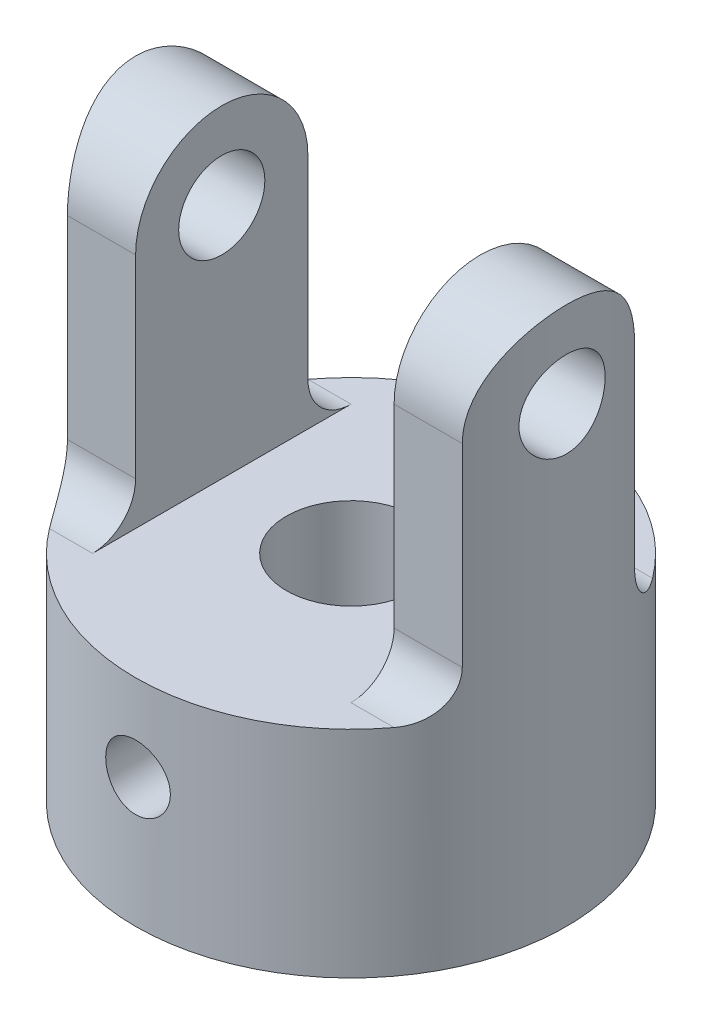
from build123d import *

# Parameters (mm, degrees)
SKETCH_1_W          = 20
SKETCH_1_H          = 20
EXTRUDE_1_DEPTH     = 10
SKETCH_2_R          = 2
EXTRUDE_2_DEPTH     = 10
SKETCH_2_2_R        = 2
CUT_EXTRUDE_1_DEPTH = 6
SKETCH_4_OUTSIDE_W  = 29.55
SKETCH_4_OUTSIDE_H  = 29.55
SKETCH_4_OUTSIDE_R  = 10
CUT_EXTRUDE_2_DEPTH = 29.722813233
SKETCH_5_R          = 3
CUT_EXTRUDE_3_DEPTH = 29.722813389
SKETCH_6_R          = 1.5
CUT_EXTRUDE_4_DEPTH = 29.722813389
FILLET_1_R          = 2


with BuildPart() as part:
    # 草圖1 → 填料-伸長1 (new body)
    with BuildSketch(Plane(origin=(0, 0, 0), x_dir=(1, 0, 0), z_dir=(0, 1, 0))):
        Rectangle(SKETCH_1_W, SKETCH_1_H)
    extrude(amount=EXTRUDE_1_DEPTH)

    # 草圖2 → 填料-伸長2 (add, symmetric)
    with BuildSketch(Plane(origin=(0, 0, 0), x_dir=(0, 0, -1), z_dir=(1, 0, 0))):
        with BuildLine():
            Line((4, 10), (4, 21))
            ThreePointArc((4, 21), (0, 25), (-4, 21))
            Line((-4, 21), (-4, 10))
            Line((-4, 10), (4, 10))
        make_face()
        with Locations((0, 21)):
            Circle(SKETCH_2_R, mode=Mode.SUBTRACT)
    extrude(amount=EXTRUDE_2_DEPTH, both=True)

    # 草圖2<2> → 除料-伸長1 (cut, symmetric)
    with BuildSketch(Plane(origin=(0, 0, 0), x_dir=(0, 0, -1), z_dir=(1, 0, 0))):
        with BuildLine():
            Line((4, 10), (4, 21))
            ThreePointArc((4, 21), (0, 25), (-4, 21))
            Line((-4, 21), (-4, 10))
            Line((-4, 10), (4, 10))
        make_face()
        with Locations((0, 21)):
            Circle(SKETCH_2_2_R, mode=Mode.SUBTRACT)
    extrude(amount=CUT_EXTRUDE_1_DEPTH, both=True, mode=Mode.SUBTRACT)

    # 草圖4 outside → 除料-伸長2 (cut, through all)
    with BuildSketch(Plane(origin=(0, 0, 0), x_dir=(1, 0, 0), z_dir=(0, 1, 0))):
        Rectangle(SKETCH_4_OUTSIDE_W, SKETCH_4_OUTSIDE_H)
        Circle(SKETCH_4_OUTSIDE_R, mode=Mode.SUBTRACT)
    extrude(amount=CUT_EXTRUDE_2_DEPTH, mode=Mode.SUBTRACT)

    # 草圖5 → 除料-伸長3 (cut, through all)
    with BuildSketch(Plane.XZ):
        Circle(SKETCH_5_R)
    extrude(amount=-CUT_EXTRUDE_3_DEPTH, mode=Mode.SUBTRACT)

    # 草圖6 → 除料-伸長4 (cut, through all)
    with BuildSketch(Plane.XY):
        with Locations((0, 6)):
            Circle(SKETCH_6_R)
    extrude(amount=CUT_EXTRUDE_4_DEPTH, mode=Mode.SUBTRACT)

    # 圓角1
    fillet_1_edges = [part.edges().sort_by_distance(p)[0] for p in [
        (-7.582575695, 10, -4),
        (7.582575695, 10, -4),
        (-7.582575695, 10, 4),
        (7.582575695, 10, 4),
    ]]
    fillet(fillet_1_edges, radius=FILLET_1_R)


solid = part.part
